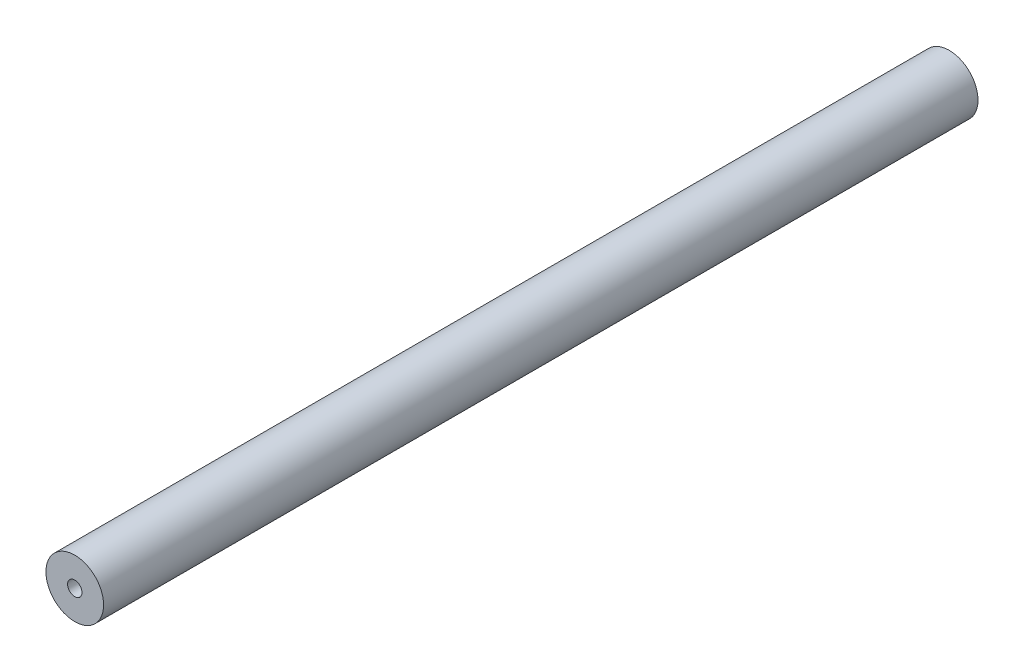
from build123d import *

# Parameters (mm, degrees)
SKETCH_1_R          = 6
EXTRUDE_1_DEPTH     = 182
SKETCH_2_R          = 1.5
CUT_EXTRUDE_1_DEPTH = 8.8
SKETCH_7_R          = 1.5
CUT_EXTRUDE_2_DEPTH = 8.8


with BuildPart() as part:
    # ｽｹｯﾁ1 → ﾎﾞｽ - 押し出し1 (new body)
    with BuildSketch(Plane.XY):
        Circle(SKETCH_1_R)
    extrude(amount=EXTRUDE_1_DEPTH)

    # ｽｹｯﾁ2 → ｶｯﾄ - 押し出し1 (cut)
    with BuildSketch(Plane.XY.offset(182)):
        Circle(SKETCH_2_R)
    extrude(amount=-CUT_EXTRUDE_1_DEPTH, mode=Mode.SUBTRACT)

    # ｽｹｯﾁ7 → ｶｯﾄ - 押し出し2 (cut)
    with BuildSketch(Plane(origin=(0, 0, 0), x_dir=(-1, 0, 0), z_dir=(0, 0, -1))):
        Circle(SKETCH_7_R)
    extrude(amount=-CUT_EXTRUDE_2_DEPTH, mode=Mode.SUBTRACT)


solid = part.part
